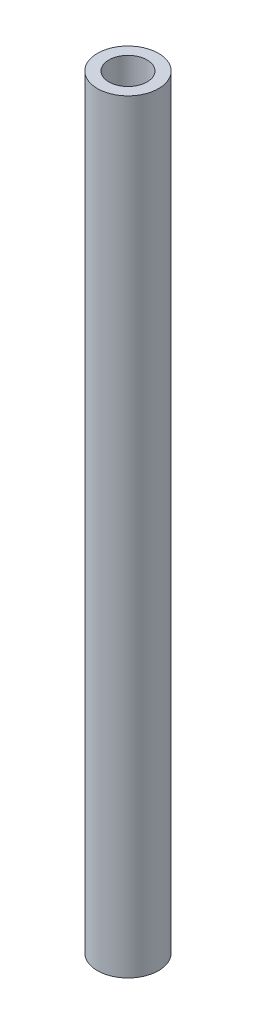
from build123d import *

# Parameters (mm, degrees)
SKETCH1_R           = 5.08
BOSS_EXTRUDE1_DEPTH = 127
SKETCH2_R           = 3.175
CUT_EXTRUDE1_DEPTH  = 128


with BuildPart() as part:
    # Sketch1 → Boss-Extrude1 (new body)
    with BuildSketch(Plane(origin=(0, 0, 0), x_dir=(1, 0, 0), z_dir=(0, 1, 0))):
        Circle(SKETCH1_R)
    extrude(amount=BOSS_EXTRUDE1_DEPTH)

    # Sketch2 → Cut-Extrude1 (cut, through all)
    with BuildSketch(Plane.XZ):
        Circle(SKETCH2_R)
    extrude(amount=-CUT_EXTRUDE1_DEPTH, mode=Mode.SUBTRACT)


solid = part.part
